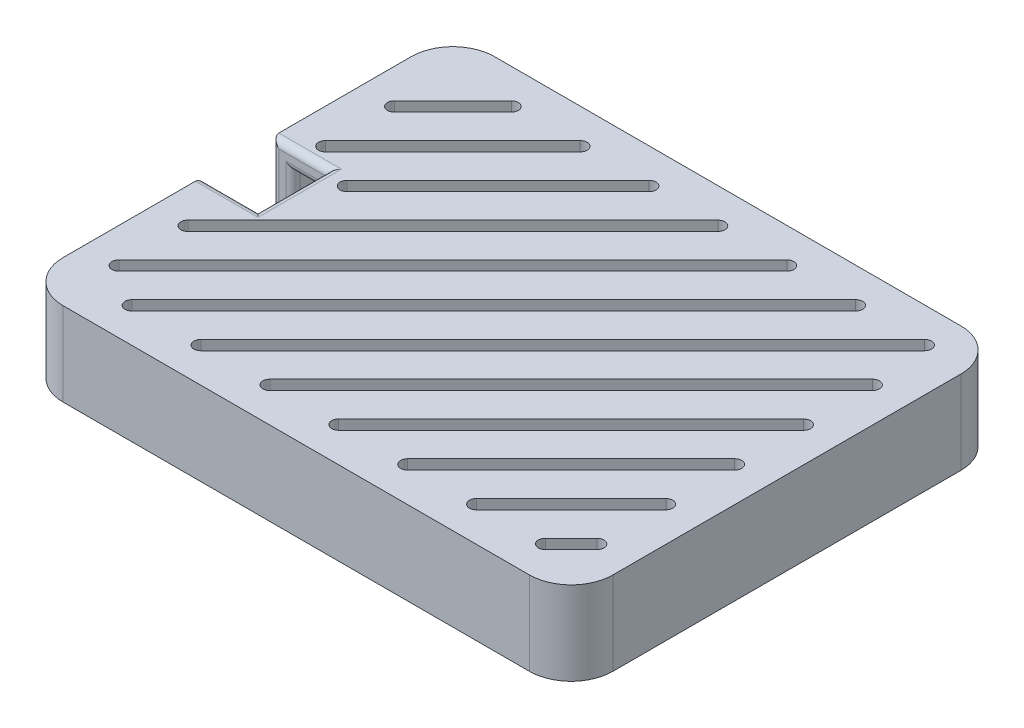
from build123d import *

# Parameters (mm, degrees)
RESSALTO_EXTRUS_O1_DEPTH = 12
CASCA1_T                 = -3
ESBO_O3_W                = 8
ESBO_O3_H                = 10
CORTE_EXTRUS_O2_DEPTH    = 13
FILETE1_R                = 1
CORTE_EXTRUS_O5_REACH    = 14


with BuildPart() as part:
    # Esboço2 → Ressalto-extrusão1 (new body)
    with BuildSketch(Plane(origin=(0, 5.997724004, 0), x_dir=(1, 0, 0), z_dir=(0, 1, 0))):
        with BuildLine():
            Line((-58.558389249, -55.520655269), (-58.558389249, -105.520655269))
            ThreePointArc((-58.558389249, -105.520655269), (-56.801029936, -109.763295956), (-52.558389249, -111.520655269))
            Line((-52.558389249, -111.520655269), (14.441610751, -111.520655269))
            ThreePointArc((14.441610751, -111.520655269), (18.684251438, -109.763295956), (20.441610751, -105.520655269))
            Line((20.441610751, -105.520655269), (20.441610751, -55.520655269))
            ThreePointArc((20.441610751, -55.520655269), (18.684251438, -51.278014582), (14.441610751, -49.520655269))
            Line((14.441610751, -49.520655269), (-52.558389249, -49.520655269))
            ThreePointArc((-52.558389249, -49.520655269), (-56.801029936, -51.278014582), (-58.558389249, -55.520655269))
        make_face()
    extrude(amount=-RESSALTO_EXTRUS_O1_DEPTH)

    # Casca1
    casca1_openings = [part.faces().sort_by_distance(p)[0] for p in [
        (-19.058389249, -6.002275996, 80.520655269),
    ]]
    offset(amount=CASCA1_T, openings=casca1_openings, kind=Kind.INTERSECTION)

    # Esboço3 → Corte-extrusão2 (cut, through all)
    with BuildSketch(Plane(origin=(0, 5.997724004, 0), x_dir=(1, 0, 0), z_dir=(0, 1, 0))):
        with Locations((-54.558389249, -80.520655269)):
            Rectangle(ESBO_O3_W, ESBO_O3_H)
    extrude(amount=-CORTE_EXTRUS_O2_DEPTH, mode=Mode.SUBTRACT)

    # Filete1
    filete1_edges = [part.edges().sort_by_distance(p)[0] for p in [
        (-53.058389249, 2.997724004, 85.520655269),
        (-50.558389249, 2.997724004, 80.520655269),
        (-53.058389249, 2.997724004, 75.520655269),
        (-55.558389249, -1.502275996, 75.520655269),
        (-58.558389249, -0.002275996, 75.520655269),
        (-55.558389249, -1.502275996, 85.520655269),
        (-58.558389249, -0.002275996, 85.520655269),
        (-54.558389249, 5.997724004, 85.520655269),
        (-50.558389249, 5.997724004, 80.520655269),
        (-54.558389249, 5.997724004, 75.520655269),
    ]]
    fillet(filete1_edges, radius=FILETE1_R)

    # Esboço8 → Corte-extrusão5 (cut, up to next)
    with BuildSketch(Plane(origin=(0, 5.997724004, 0), x_dir=(1, 0, 0), z_dir=(0, 1, 0)), mode=Mode.PRIVATE) as corte_extrus_o5_sk1:
        with BuildLine():
            Line((-54.26549603, -62.209172871), (-45.869871648, -53.813548488))
            ThreePointArc((-45.869871648, -53.813548488), (-44.455658085, -53.813548488), (-44.455658085, -55.22776205))
            Line((-44.455658085, -55.22776205), (-52.851282468, -63.623386433))
            ThreePointArc((-52.851282468, -63.623386433), (-54.26549603, -63.623386433), (-54.26549603, -62.209172871))
        make_face()
    corte_extrus_o5_tool1 = extrude(corte_extrus_o5_sk1.sketch, amount=-CORTE_EXTRUS_O5_REACH, mode=Mode.PRIVATE) & part.part
    add(corte_extrus_o5_tool1.solids().sort_by_distance((-49.360577, 5.997724, 58.718467))[0], mode=Mode.SUBTRACT)
    # Esboço8 → Corte-extrusão5 (cut, up to next)
    with BuildSketch(Plane(origin=(0, 5.997724004, 0), x_dir=(1, 0, 0), z_dir=(0, 1, 0)), mode=Mode.PRIVATE) as corte_extrus_o5_sk2:
        with BuildLine():
            Line((-54.26549603, -72.108667807), (-35.970376711, -53.813548488))
            ThreePointArc((-35.970376711, -53.813548488), (-34.556163149, -53.813548488), (-34.556163149, -55.22776205))
            Line((-34.556163149, -55.22776205), (-52.851282468, -73.52288137))
            ThreePointArc((-52.851282468, -73.52288137), (-54.26549603, -73.52288137), (-54.26549603, -72.108667807))
        make_face()
    corte_extrus_o5_tool2 = extrude(corte_extrus_o5_sk2.sketch, amount=-CORTE_EXTRUS_O5_REACH, mode=Mode.PRIVATE) & part.part
    add(corte_extrus_o5_tool2.solids().sort_by_distance((-44.41083, 5.997724, 63.668215))[0], mode=Mode.SUBTRACT)
    # Esboço8 → Corte-extrusão5 (cut, up to next)
    with BuildSketch(Plane(origin=(0, 5.997724004, 0), x_dir=(1, 0, 0), z_dir=(0, 1, 0)), mode=Mode.PRIVATE) as corte_extrus_o5_sk3:
        with BuildLine():
            Line((-47.76549603, -75.508162744), (-26.070881774, -53.813548488))
            ThreePointArc((-26.070881774, -53.813548488), (-24.656668212, -53.813548488), (-24.656668212, -55.22776205))
            Line((-24.656668212, -55.22776205), (-46.351282468, -76.922376306))
            ThreePointArc((-46.351282468, -76.922376306), (-47.76549603, -76.922376306), (-47.76549603, -75.508162744))
        make_face()
    corte_extrus_o5_tool3 = extrude(corte_extrus_o5_sk3.sketch, amount=-CORTE_EXTRUS_O5_REACH, mode=Mode.PRIVATE) & part.part
    add(corte_extrus_o5_tool3.solids().sort_by_distance((-36.211082, 5.997724, 65.367962))[0], mode=Mode.SUBTRACT)
    # Esboço8 → Corte-extrusão5 (cut, up to next)
    with BuildSketch(Plane(origin=(0, 5.997724004, 0), x_dir=(1, 0, 0), z_dir=(0, 1, 0)), mode=Mode.PRIVATE) as corte_extrus_o5_sk4:
        with BuildLine():
            Line((-54.26549603, -91.90765768), (-16.171386838, -53.813548488))
            ThreePointArc((-16.171386838, -53.813548488), (-14.757173275, -53.813548488), (-14.757173275, -55.22776205))
            Line((-14.757173275, -55.22776205), (-52.851282468, -93.321871243))
            ThreePointArc((-52.851282468, -93.321871243), (-54.26549603, -93.321871243), (-54.26549603, -91.90765768))
        make_face()
    corte_extrus_o5_tool4 = extrude(corte_extrus_o5_sk4.sketch, amount=-CORTE_EXTRUS_O5_REACH, mode=Mode.PRIVATE) & part.part
    add(corte_extrus_o5_tool4.solids().sort_by_distance((-34.511335, 5.997724, 73.56771))[0], mode=Mode.SUBTRACT)
    # Esboço8 → Corte-extrusão5 (cut, up to next)
    with BuildSketch(Plane(origin=(0, 5.997724004, 0), x_dir=(1, 0, 0), z_dir=(0, 1, 0)), mode=Mode.PRIVATE) as corte_extrus_o5_sk5:
        with BuildLine():
            Line((-4.857678339, -55.22776205), (-52.851282468, -103.221366179))
            ThreePointArc((-52.851282468, -103.221366179), (-54.26549603, -103.221366179), (-54.26549603, -101.807152617))
            Line((-54.26549603, -101.807152617), (-6.271891901, -53.813548488))
            ThreePointArc((-6.271891901, -53.813548488), (-4.857678339, -53.813548488), (-4.857678339, -55.22776205))
        make_face()
    corte_extrus_o5_tool5 = extrude(corte_extrus_o5_sk5.sketch, amount=-CORTE_EXTRUS_O5_REACH, mode=Mode.PRIVATE) & part.part
    add(corte_extrus_o5_tool5.solids().sort_by_distance((-29.561587, 5.997724, 78.517457))[0], mode=Mode.SUBTRACT)
    # Esboço8 → Corte-extrusão5 (cut, up to next)
    with BuildSketch(Plane(origin=(0, 5.997724004, 0), x_dir=(1, 0, 0), z_dir=(0, 1, 0)), mode=Mode.PRIVATE) as corte_extrus_o5_sk6:
        with BuildLine():
            Line((-48.372396965, -105.813548488), (3.627603035, -53.813548488))
            ThreePointArc((3.627603035, -53.813548488), (5.041816598, -53.813548488), (5.041816598, -55.22776205))
            Line((5.041816598, -55.22776205), (-46.958183402, -107.22776205))
            ThreePointArc((-46.958183402, -107.22776205), (-48.372396965, -107.22776205), (-48.372396965, -105.813548488))
        make_face()
    corte_extrus_o5_tool6 = extrude(corte_extrus_o5_sk6.sketch, amount=-CORTE_EXTRUS_O5_REACH, mode=Mode.PRIVATE) & part.part
    add(corte_extrus_o5_tool6.solids().sort_by_distance((-21.66529, 5.997724, 80.520655))[0], mode=Mode.SUBTRACT)
    # Esboço8 → Corte-extrusão5 (cut, up to next)
    with BuildSketch(Plane(origin=(0, 5.997724004, 0), x_dir=(1, 0, 0), z_dir=(0, 1, 0)), mode=Mode.PRIVATE) as corte_extrus_o5_sk7:
        with BuildLine():
            Line((14.941311534, -55.22776205), (-37.058688466, -107.22776205))
            ThreePointArc((-37.058688466, -107.22776205), (-38.472902028, -107.22776205), (-38.472902028, -105.813548488))
            Line((-38.472902028, -105.813548488), (13.527097972, -53.813548488))
            ThreePointArc((13.527097972, -53.813548488), (14.941311534, -53.813548488), (14.941311534, -55.22776205))
        make_face()
    corte_extrus_o5_tool7 = extrude(corte_extrus_o5_sk7.sketch, amount=-CORTE_EXTRUS_O5_REACH, mode=Mode.PRIVATE) & part.part
    add(corte_extrus_o5_tool7.solids().sort_by_distance((-11.765795, 5.997724, 80.520655))[0], mode=Mode.SUBTRACT)
    # Esboço8 → Corte-extrusão5 (cut, up to next)
    with BuildSketch(Plane(origin=(0, 5.997724004, 0), x_dir=(1, 0, 0), z_dir=(0, 1, 0)), mode=Mode.PRIVATE) as corte_extrus_o5_sk8:
        with BuildLine():
            Line((-28.573407091, -105.813548488), (14.73450397, -62.505637427))
            ThreePointArc((14.73450397, -62.505637427), (16.148717532, -62.505637427), (16.148717532, -63.919850989))
            Line((16.148717532, -63.919850989), (-27.159193529, -107.22776205))
            ThreePointArc((-27.159193529, -107.22776205), (-28.573407091, -107.22776205), (-28.573407091, -105.813548488))
        make_face()
    corte_extrus_o5_tool8 = extrude(corte_extrus_o5_sk8.sketch, amount=-CORTE_EXTRUS_O5_REACH, mode=Mode.PRIVATE) & part.part
    add(corte_extrus_o5_tool8.solids().sort_by_distance((-6.212345, 5.997724, 84.8667))[0], mode=Mode.SUBTRACT)
    # Esboço8 → Corte-extrusão5 (cut, up to next)
    with BuildSketch(Plane(origin=(0, 5.997724004, 0), x_dir=(1, 0, 0), z_dir=(0, 1, 0)), mode=Mode.PRIVATE) as corte_extrus_o5_sk9:
        with BuildLine():
            Line((16.148717532, -73.819345926), (-17.259698592, -107.22776205))
            ThreePointArc((-17.259698592, -107.22776205), (-18.673912155, -107.22776205), (-18.673912155, -105.813548488))
            Line((-18.673912155, -105.813548488), (14.73450397, -72.405132363))
            ThreePointArc((14.73450397, -72.405132363), (16.148717532, -72.405132363), (16.148717532, -73.819345926))
        make_face()
    corte_extrus_o5_tool9 = extrude(corte_extrus_o5_sk9.sketch, amount=-CORTE_EXTRUS_O5_REACH, mode=Mode.PRIVATE) & part.part
    add(corte_extrus_o5_tool9.solids().sort_by_distance((-1.262597, 5.997724, 89.816447))[0], mode=Mode.SUBTRACT)
    # Esboço8 → Corte-extrusão5 (cut, up to next)
    with BuildSketch(Plane(origin=(0, 5.997724004, 0), x_dir=(1, 0, 0), z_dir=(0, 1, 0)), mode=Mode.PRIVATE) as corte_extrus_o5_sk10:
        with BuildLine():
            Line((-8.774417218, -105.813548488), (14.73450397, -82.3046273))
            ThreePointArc((14.73450397, -82.3046273), (16.148717532, -82.3046273), (16.148717532, -83.718840862))
            Line((16.148717532, -83.718840862), (-7.360203656, -107.22776205))
            ThreePointArc((-7.360203656, -107.22776205), (-8.774417218, -107.22776205), (-8.774417218, -105.813548488))
        make_face()
    corte_extrus_o5_tool10 = extrude(corte_extrus_o5_sk10.sketch, amount=-CORTE_EXTRUS_O5_REACH, mode=Mode.PRIVATE) & part.part
    add(corte_extrus_o5_tool10.solids().sort_by_distance((3.68715, 5.997724, 94.766195))[0], mode=Mode.SUBTRACT)
    # Esboço8 → Corte-extrusão5 (cut, up to next)
    with BuildSketch(Plane(origin=(0, 5.997724004, 0), x_dir=(1, 0, 0), z_dir=(0, 1, 0)), mode=Mode.PRIVATE) as corte_extrus_o5_sk11:
        with BuildLine():
            Line((16.148717532, -93.618335799), (2.539291281, -107.22776205))
            ThreePointArc((2.539291281, -107.22776205), (1.125077719, -107.22776205), (1.125077719, -105.813548488))
            Line((1.125077719, -105.813548488), (14.73450397, -92.204122237))
            ThreePointArc((14.73450397, -92.204122237), (16.148717532, -92.204122237), (16.148717532, -93.618335799))
        make_face()
    corte_extrus_o5_tool11 = extrude(corte_extrus_o5_sk11.sketch, amount=-CORTE_EXTRUS_O5_REACH, mode=Mode.PRIVATE) & part.part
    add(corte_extrus_o5_tool11.solids().sort_by_distance((8.636898, 5.997724, 99.715942))[0], mode=Mode.SUBTRACT)
    # Esboço8 → Corte-extrusão5 (cut, up to next)
    with BuildSketch(Plane(origin=(0, 5.997724004, 0), x_dir=(1, 0, 0), z_dir=(0, 1, 0)), mode=Mode.PRIVATE) as corte_extrus_o5_sk12:
        with BuildLine():
            Line((11.024572655, -105.813548488), (14.73450397, -102.103617173))
            ThreePointArc((14.73450397, -102.103617173), (16.148717532, -102.103617173), (16.148717532, -103.517830736))
            Line((16.148717532, -103.517830736), (12.438786218, -107.22776205))
            ThreePointArc((12.438786218, -107.22776205), (11.024572655, -107.22776205), (11.024572655, -105.813548488))
        make_face()
    corte_extrus_o5_tool12 = extrude(corte_extrus_o5_sk12.sketch, amount=-CORTE_EXTRUS_O5_REACH, mode=Mode.PRIVATE) & part.part
    add(corte_extrus_o5_tool12.solids().sort_by_distance((13.586645, 5.997724, 104.66569))[0], mode=Mode.SUBTRACT)


solid = part.part
